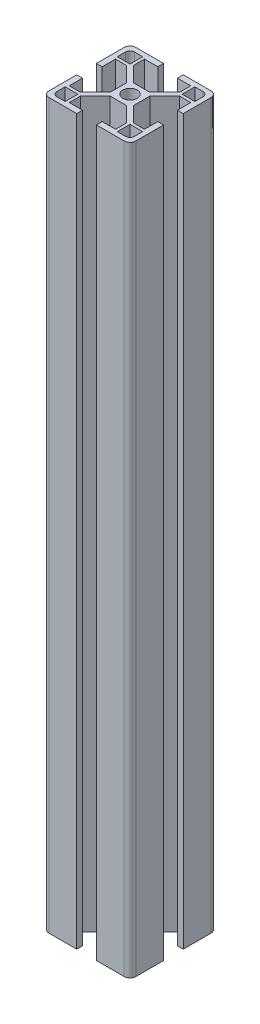
from build123d import *

# Parameters (mm, degrees)
BOSS_EXTRUDE1_DEPTH = 250


with BuildPart() as part:
    # Sketch1 → Boss-Extrude1 (new body)
    with BuildSketch(Plane(origin=(0, 0, 0), x_dir=(1, 0, 0), z_dir=(0, 1, 0))):
        with BuildLine():
            Line((0, 28), (0, 18.4))
            Line((0, 18.4), (2, 18.4))
            Line((2, 18.4), (2, 23))
            Line((2, 23), (5.833273811, 23))
            Line((5.833273811, 23), (11, 17.833273811))
            Line((11, 17.833273811), (11, 15))
            Line((11, 15), (11, 12.166726189))
            Line((11, 12.166726189), (5.833273811, 7))
            Line((5.833273811, 7), (2, 7))
            Line((2, 7), (2, 11.6))
            Line((2, 11.6), (0, 11.6))
            Line((0, 11.6), (0, 2))
            ThreePointArc((0, 2), (0.585786438, 0.585786438), (2, 0))
            Line((2, 0), (11.6, 0))
            Line((11.6, 0), (11.6, 2))
            Line((11.6, 2), (7, 2))
            Line((7, 2), (7, 5.833273811))
            Line((7, 5.833273811), (12.166726189, 11))
            Line((12.166726189, 11), (15, 11))
            Line((15, 11), (17.833273811, 11))
            Line((17.833273811, 11), (23, 5.833273811))
            Line((23, 5.833273811), (23, 2))
            Line((23, 2), (18.4, 2))
            Line((18.4, 2), (18.4, 0))
            Line((18.4, 0), (28, 0))
            ThreePointArc((28, 0), (29.414213562, 0.585786438), (30, 2))
            Line((30, 2), (30, 11.6))
            Line((30, 11.6), (28, 11.6))
            Line((28, 11.6), (28, 7))
            Line((28, 7), (24.166726189, 7))
            Line((24.166726189, 7), (19, 12.166726189))
            Line((19, 12.166726189), (19, 15))
            Line((19, 15), (19, 17.833273811))
            Line((19, 17.833273811), (24.166726189, 23))
            Line((24.166726189, 23), (28, 23))
            Line((28, 23), (28, 18.4))
            Line((28, 18.4), (30, 18.4))
            Line((30, 18.4), (30, 28))
            ThreePointArc((30, 28), (29.414213562, 29.414213562), (28, 30))
            Line((28, 30), (18.4, 30))
            Line((18.4, 30), (18.4, 28))
            Line((18.4, 28), (23, 28))
            Line((23, 28), (23, 24.166726189))
            Line((23, 24.166726189), (17.833273811, 19))
            Line((17.833273811, 19), (15, 19))
            Line((15, 19), (12.166726189, 19))
            Line((12.166726189, 19), (7, 24.166726189))
            Line((7, 24.166726189), (7, 28))
            Line((7, 28), (11.6, 28))
            Line((11.6, 28), (11.6, 30))
            Line((11.6, 30), (2, 30))
            ThreePointArc((2, 30), (0.585786438, 29.414213562), (0, 28))
        make_face()
        with BuildLine():
            Line((6, 28.4), (6, 24))
            Line((6, 24), (1.6, 24))
            Line((1.6, 24), (1.6, 26.8))
            ThreePointArc((1.6, 26.8), (2.06862915, 27.93137085), (3.2, 28.4))
            Line((3.2, 28.4), (6, 28.4))
        make_face(mode=Mode.SUBTRACT)
        with BuildLine():
            Line((26.8, 28.4), (24, 28.4))
            Line((24, 28.4), (24, 24))
            Line((24, 24), (28.4, 24))
            Line((28.4, 24), (28.4, 26.8))
            ThreePointArc((28.4, 26.8), (27.93137085, 27.93137085), (26.8, 28.4))
        make_face(mode=Mode.SUBTRACT)
        with BuildLine():
            Line((28.4, 3.2), (28.4, 6))
            Line((28.4, 6), (24, 6))
            Line((24, 6), (24, 1.6))
            Line((24, 1.6), (26.8, 1.6))
            ThreePointArc((26.8, 1.6), (27.93137085, 2.06862915), (28.4, 3.2))
        make_face(mode=Mode.SUBTRACT)
        with BuildLine():
            Line((3.2, 1.6), (6, 1.6))
            Line((6, 1.6), (6, 6))
            Line((6, 6), (1.6, 6))
            Line((1.6, 6), (1.6, 3.2))
            ThreePointArc((1.6, 3.2), (2.06862915, 2.06862915), (3.2, 1.6))
        make_face(mode=Mode.SUBTRACT)
        with BuildLine():
            ThreePointArc((15, 17.5), (13.232233047, 16.767766953), (12.5, 15))
            ThreePointArc((12.5, 15), (13.232233047, 13.232233047), (15, 12.5))
            ThreePointArc((15, 12.5), (16.767766953, 13.232233047), (17.5, 15))
            ThreePointArc((17.5, 15), (16.767766953, 16.767766953), (15, 17.5))
        make_face(mode=Mode.SUBTRACT)
    extrude(amount=BOSS_EXTRUDE1_DEPTH)


solid = part.part
